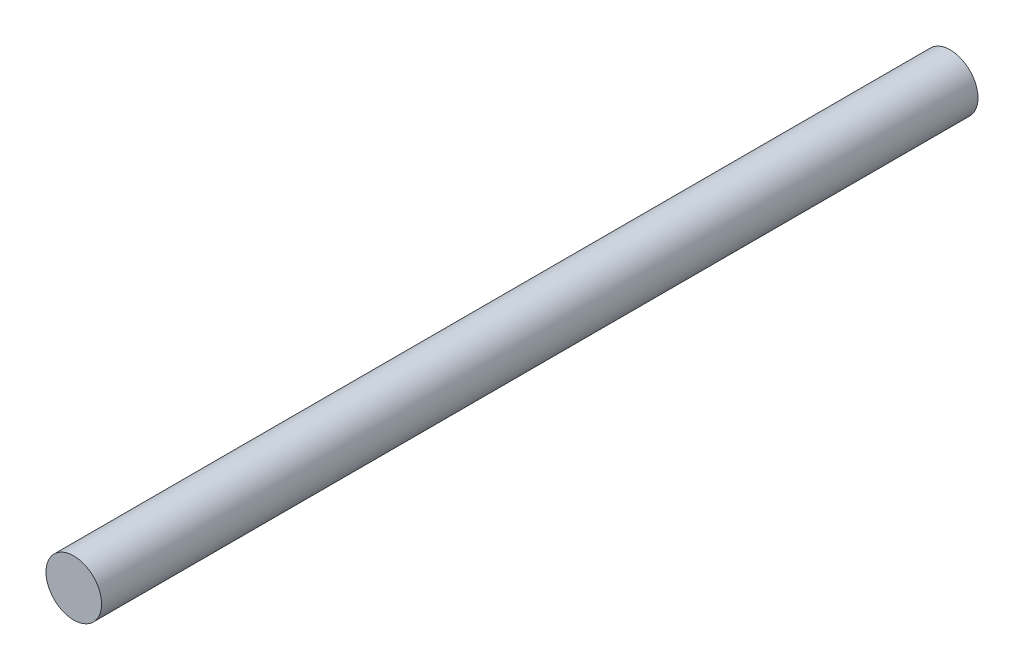
from build123d import *

# Parameters (mm, degrees)
ESQUISSE2_R        = 2.95
BOSS_EXTRU_1_DEPTH = 93


with BuildPart() as part:
    # Esquisse2 → Boss.-Extru.1 (new body)
    with BuildSketch(Plane.XY):
        Circle(ESQUISSE2_R)
    extrude(amount=BOSS_EXTRU_1_DEPTH)


solid = part.part
